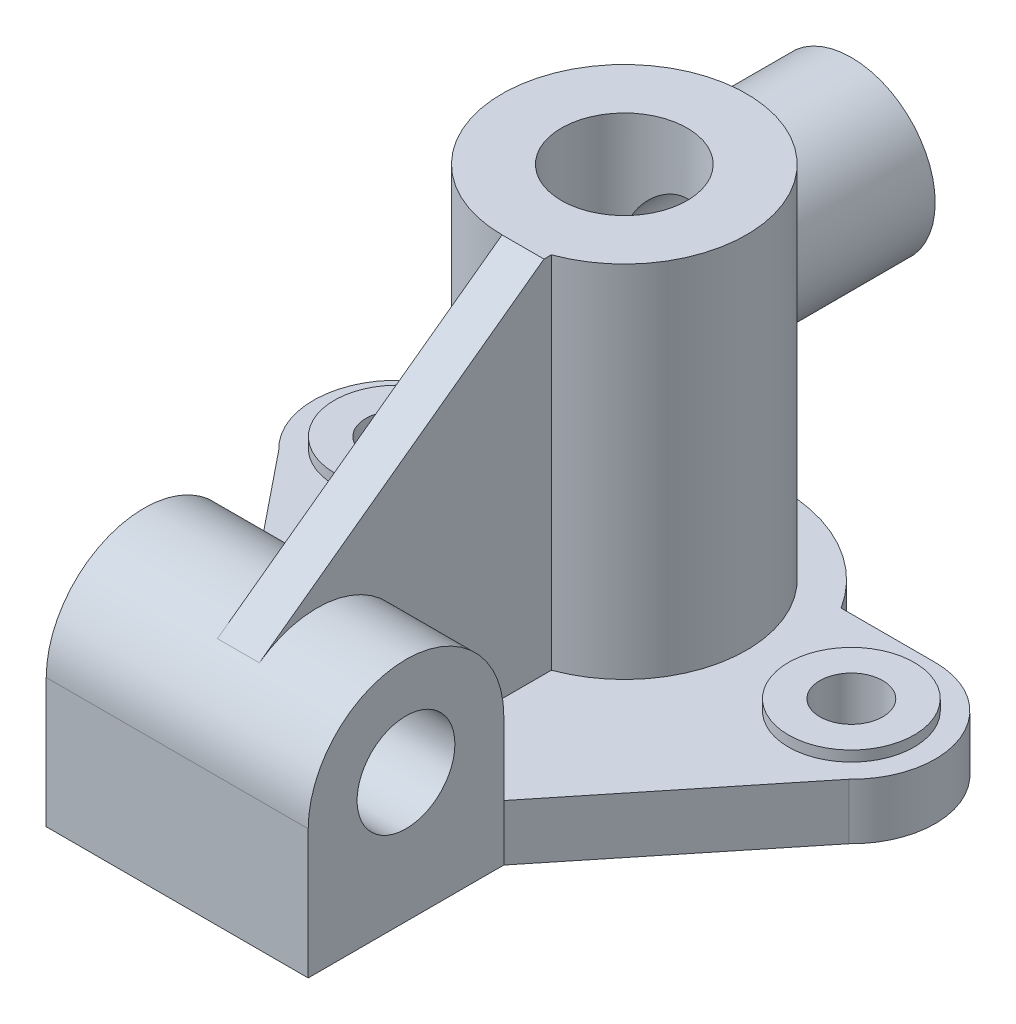
from build123d import *

# Parameters (mm, degrees)
CROQUIS2_R              = 18
CROQUIS2_R_2            = 9
SALIENTE_EXTRUIR1_DEPTH = 16
CROQUIS3_R              = 18
CROQUIS3_R_2            = 9
SALIENTE_EXTRUIR2_DEPTH = 19
CROQUIS4_R              = 35
CROQUIS4_R_2            = 18
SALIENTE_EXTRUIR3_DEPTH = 119
CROQUIS5_R              = 14
SALIENTE_EXTRUIR4_DEPTH = 37.5
SALIENTE_EXTRUIR5_DEPTH = 12
SALIENTE_EXTRUIR6_REACH = 195
CROQUIS7_R              = 24
CROQUIS7_R_2            = 12.5
CORTAR_EXTRUIR1_REACH   = 195
CROQUIS8_R              = 12.5


with BuildPart() as part:
    # Croquis2 → Saliente-Extruir1 (new body)
    with BuildSketch(Plane(origin=(0, 0, 0), x_dir=(1, 0, 0), z_dir=(0, 1, 0))):
        with BuildLine():
            Line((-65, 24), (-38.065732621, 24))
            ThreePointArc((-38.065732621, 24), (0, 45), (38.065732621, 24))
            Line((38.065732621, 24), (65, 24))
            ThreePointArc((65, 24), (87.272092101, 8.941695223), (81.595854962, -17.337173878))
            Line((81.595854962, -17.337173878), (37.5, -72))
            Line((37.5, -72), (-37.5, -72))
            Line((-37.5, -72), (-81.595854962, -17.337173878))
            ThreePointArc((-81.595854962, -17.337173878), (-87.272092101, 8.941695223), (-65, 24))
        make_face()
        Circle(CROQUIS2_R, mode=Mode.SUBTRACT)
        with Locations((65, 0)):
            Circle(CROQUIS2_R_2, mode=Mode.SUBTRACT)
        with Locations((-65, 0)):
            Circle(CROQUIS2_R_2, mode=Mode.SUBTRACT)
    extrude(amount=SALIENTE_EXTRUIR1_DEPTH)

    # Croquis3 → Saliente-Extruir2 (add)
    with BuildSketch(Plane(origin=(0, 0, 0), x_dir=(1, 0, 0), z_dir=(0, 1, 0))):
        with Locations((65, 0)):
            Circle(CROQUIS3_R)
        with Locations((65, 0)):
            Circle(CROQUIS3_R_2, mode=Mode.SUBTRACT)
        with Locations((-65, 0)):
            Circle(CROQUIS3_R)
        with Locations((-65, 0)):
            Circle(CROQUIS3_R_2, mode=Mode.SUBTRACT)
    extrude(amount=SALIENTE_EXTRUIR2_DEPTH)

    # Croquis4 → Saliente-Extruir3 (add)
    with BuildSketch(Plane(origin=(0, 0, 0), x_dir=(1, 0, 0), z_dir=(0, 1, 0))):
        Circle(CROQUIS4_R)
        Circle(CROQUIS4_R_2, mode=Mode.SUBTRACT)
    extrude(amount=SALIENTE_EXTRUIR3_DEPTH)

    # Croquis5 → Saliente-Extruir4 (add, symmetric)
    with BuildSketch(Plane(origin=(0, 0, 0), x_dir=(0, 0, -1), z_dir=(1, 0, 0))):
        with BuildLine():
            Line((-72, 0), (-72, 37))
            ThreePointArc((-72, 37), (-100, 65), (-128, 37))
            Line((-128, 37), (-128, 0))
            Line((-128, 0), (-72, 0))
        make_face()
        with Locations((-100, 37)):
            Circle(CROQUIS5_R, mode=Mode.SUBTRACT)
    extrude(amount=SALIENTE_EXTRUIR4_DEPTH, both=True)

    # Croquis6 → Saliente-Extruir5 (add)
    with BuildSketch(Plane(origin=(0, 0, 0), x_dir=(0, 0, -1), z_dir=(1, 0, 0))):
        with BuildLine():
            Line((-72, 16), (-18, 16))
            Line((-18, 16), (-18, 119))
            Line((-18, 119), (-35, 119))
            Line((-35, 119), (-116.487939559, 59.630683797))
            ThreePointArc((-116.487939559, 59.630683797), (-87.304770732, 61.95658538), (-72, 37))
            Line((-72, 37), (-72, 16))
        make_face()
    extrude(amount=SALIENTE_EXTRUIR5_DEPTH)

    # Croquis7 → Saliente-Extruir6 (add, up to next)
    with BuildSketch(Plane.XY.offset(-65), mode=Mode.PRIVATE) as saliente_extruir6_sk1:
        with Locations((0, 89)):
            Circle(CROQUIS7_R)
        with Locations((0, 89)):
            Circle(CROQUIS7_R_2, mode=Mode.SUBTRACT)
    saliente_extruir6_tool1 = extrude(saliente_extruir6_sk1.sketch, amount=SALIENTE_EXTRUIR6_REACH, mode=Mode.PRIVATE) - part.part
    add(saliente_extruir6_tool1.solids().sort_by_distance((-23.321177, 89, -65))[0])

    # Croquis8 → Cortar-Extruir1 (cut, up to next)
    with BuildSketch(Plane.XY.offset(-65), mode=Mode.PRIVATE) as cortar_extruir1_sk1:
        with Locations((0, 89)):
            Circle(CROQUIS8_R)
    cortar_extruir1_tool1 = extrude(cortar_extruir1_sk1.sketch, amount=CORTAR_EXTRUIR1_REACH, mode=Mode.PRIVATE) & part.part
    add(cortar_extruir1_tool1.solids().sort_by_distance((0, 89, -65))[0], mode=Mode.SUBTRACT)


solid = part.part
